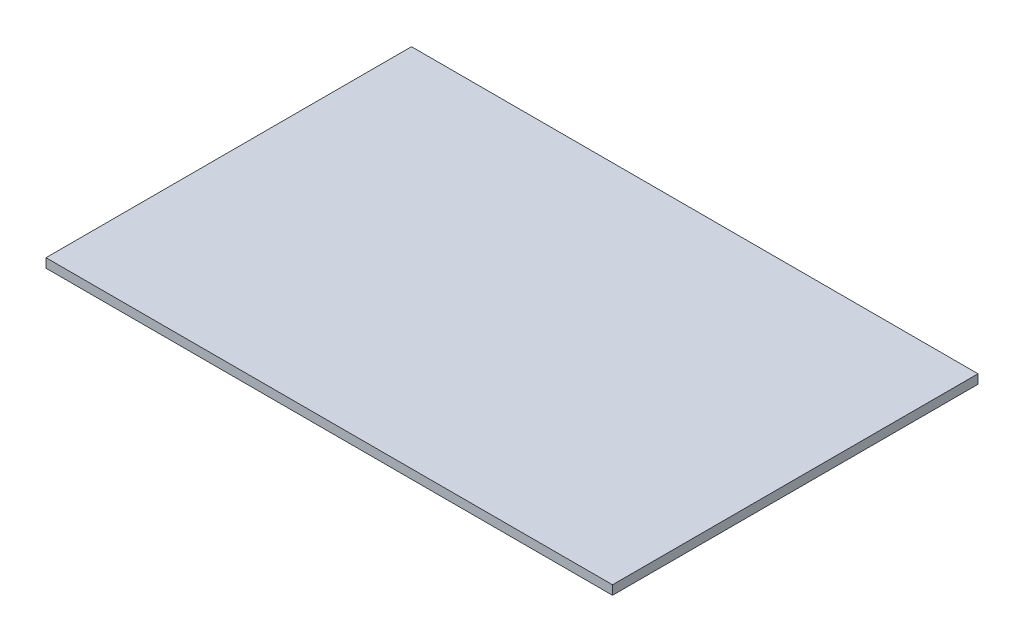
from build123d import *

# Parameters (mm, degrees)
SKETCH1_W           = 393.7
SKETCH1_H           = 254
BOSS_EXTRUDE1_DEPTH = 6.35


with BuildPart() as part:
    # Sketch1 → Boss-Extrude1 (new body)
    with BuildSketch(Plane(origin=(0, 0, 0), x_dir=(1, 0, 0), z_dir=(0, 1, 0))):
        with Locations((0, 127)):
            Rectangle(SKETCH1_W, SKETCH1_H)
    extrude(amount=BOSS_EXTRUDE1_DEPTH)


solid = part.part
